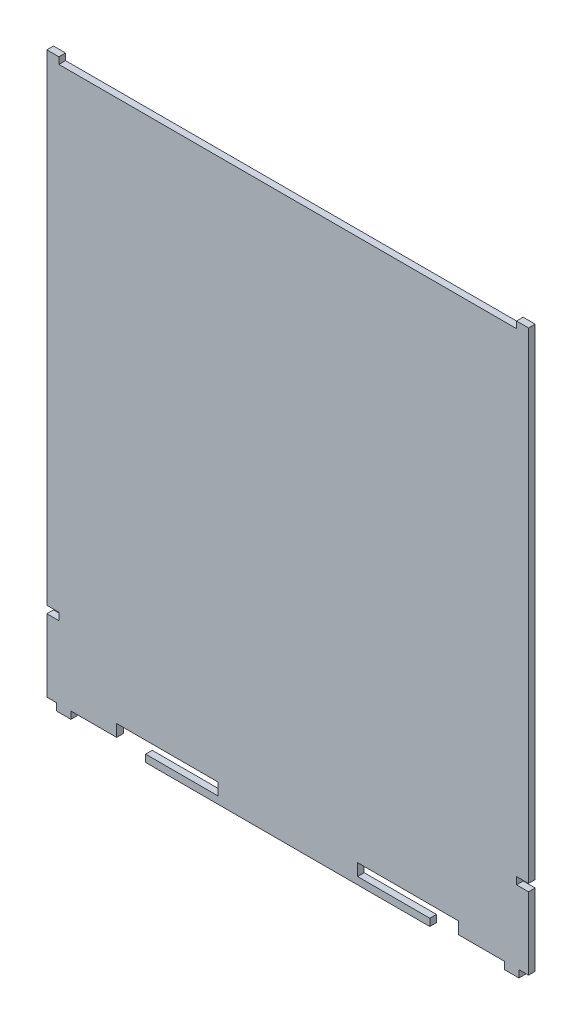
from build123d import *

# Parameters (mm, degrees)
EXTRUDE_2_DEPTH = 2.75


with BuildPart() as part:
    # 草图1 → 凸台-拉伸2 (new body)
    with BuildSketch(Plane.XY):
        Polygon((200, 0), (200, 27), (200, 30), (195, 30), (195, 33), (200, 33), (200, 230), (200, 232.75), (195, 232.75), (195, 230), (5, 230), (5, 232.75), (0, 232.75), (0, 230), (0, 33), (5, 33), (5, 30), (0, 30), (0, 27), (0, 0), (4, 0), (4, -3), (10, -3), (10, 0), (29, 0), (29, 5), (71, 5), (71, 0), (41, 0), (41, -3), (159, -3), (159, 0), (129, 0), (129, 5), (171, 5), (171, 0), (190, 0), (190, -3), (196, -3), (196, 0), align=None)
    extrude(amount=EXTRUDE_2_DEPTH)


solid = part.part
